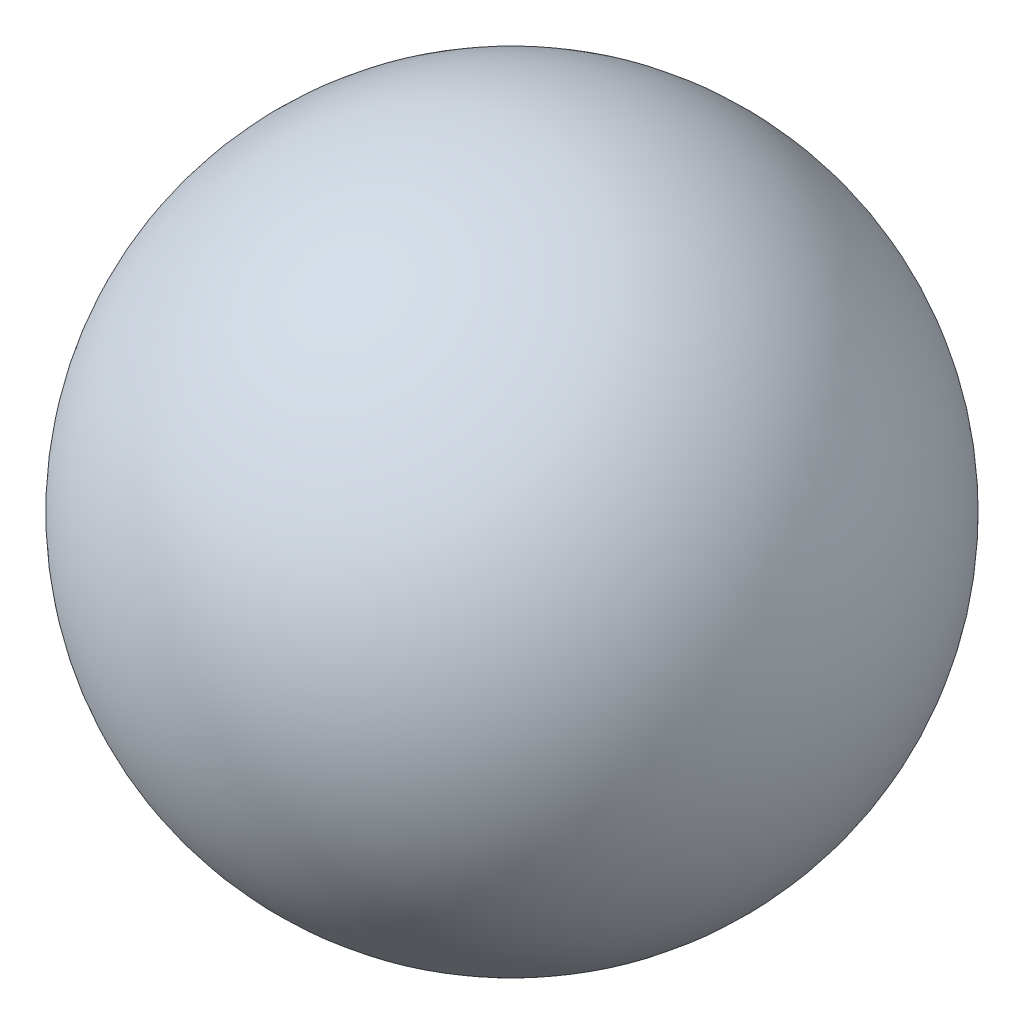
from build123d import *


with BuildPart() as part:
    # Sketch1 → Revolve1 (revolve)
    with BuildSketch(Plane.XY):
        with BuildLine():
            Line((0, -300), (0, 300))
            ThreePointArc((0, 300), (300, 0), (0, -300))
        make_face()
    revolve(axis=Axis((0, -300, 0), (0, 1, 0)))


solid = part.part
